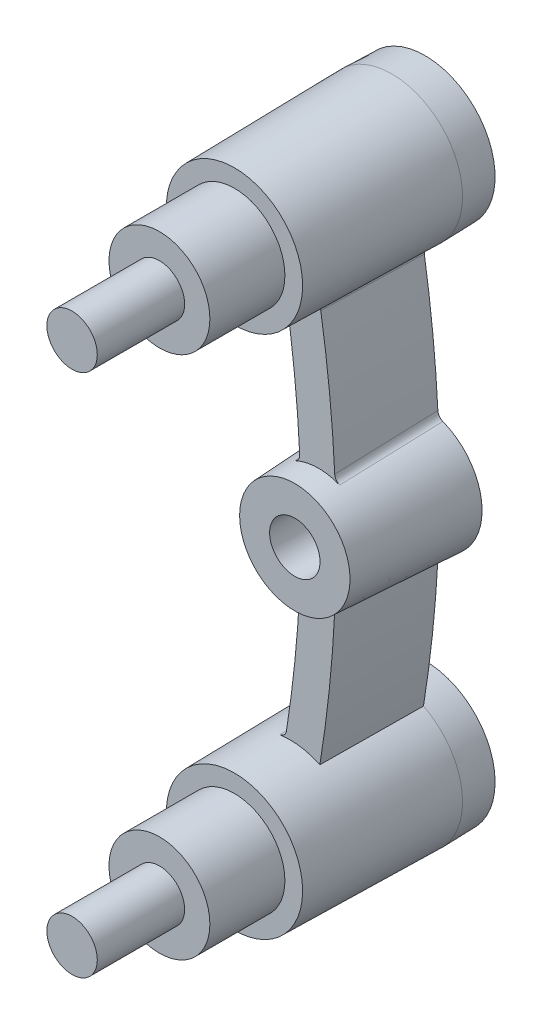
from build123d import *

# Parameters (mm, degrees)
SKETCH1_R             = 4.5
BOSS_EXTRUDE1_DEPTH   = 12
BOSS_EXTRUDE1_TAPER   = 1
BOSS_EXTRUDE1_2_DEPTH = 12
BOSS_EXTRUDE1_2_TAPER = 1
EXTRUDE_THIN1_DEPTH   = 8.5
EXTRUDE_THIN1_TAPER   = 1
SKETCH3_R             = 3.175
BOSS_EXTRUDE2_DEPTH   = 4.72352
SKETCH4_R             = 1.5875
BOSS_EXTRUDE3_DEPTH   = 5.5
SKETCH5_R             = 4
BOSS_EXTRUDE4_DEPTH   = 10
BOSS_EXTRUDE4_TAPER   = 3
SKETCH6_R             = 1.5875
CUT_EXTRUDE2_DEPTH    = 23.22352
SKETCH8_W             = 24.293622
SKETCH8_H             = 48.576804
CUT_EXTRUDE3_DEPTH    = 2.1016
CUT_EXTRUDE3_TAPER    = 3
FILLET3_R             = 0.5
SKETCH9_R             = 4.463316
BOSS_EXTRUDE5_DEPTH   = 2.1016
BOSS_EXTRUDE5_TAPER   = 1.5


with BuildPart() as part:
    # Sketch1 → Boss-Extrude1 (new body)
    with BuildSketch(Plane.XY):
        with Locations((0, -16.5)):
            Circle(SKETCH1_R)
    extrude(amount=BOSS_EXTRUDE1_DEPTH, taper=BOSS_EXTRUDE1_TAPER)



with BuildPart() as body_2:
    # Sketch1 → Boss-Extrude1 2 (new body)
    with BuildSketch(Plane.XY):
        with Locations((0, 16.5)):
            Circle(SKETCH1_R)
    extrude(amount=BOSS_EXTRUDE1_2_DEPTH, taper=BOSS_EXTRUDE1_2_TAPER)


with BuildPart() as part_1:
    add(part.part)

    add(body_2.part)  # Extrude-Thin1 merges body 2
    # Sketch2 → Extrude-Thin1 (add)
    with BuildSketch(Plane.XY):
        with BuildLine():
            ThreePointArc((-1.220598, 16.23048), (0.55, 0), (-1.220598, -16.23048))
            Line((-1.220598, -16.23048), (1.220598, -16.76952))
            ThreePointArc((1.220598, -16.76952), (3.05, 0), (1.220598, 16.76952))
            Line((1.220598, 16.76952), (-1.220598, 16.23048))
        make_face()
    extrude(amount=EXTRUDE_THIN1_DEPTH, taper=EXTRUDE_THIN1_TAPER)

    # Sketch3 → Boss-Extrude2 (add)
    with BuildSketch(Plane.XY.offset(12)):
        with Locations((0, 16.5)):
            Circle(SKETCH3_R)
        with Locations((0, -16.5)):
            Circle(SKETCH3_R)
    extrude(amount=BOSS_EXTRUDE2_DEPTH)

    # Sketch4 → Boss-Extrude3 (add)
    with BuildSketch(Plane.XY.offset(16.72352)):
        with Locations((0, 16.5)):
            Circle(SKETCH4_R)
        with Locations((0, -16.5)):
            Circle(SKETCH4_R)
    extrude(amount=BOSS_EXTRUDE3_DEPTH)

    # Sketch5 → Boss-Extrude4 (add)
    with BuildSketch(Plane(origin=(0, 0, 0), x_dir=(-1, 0, 0), z_dir=(0, 0, -1))):
        with Locations((-1.8, 0)):
            Circle(SKETCH5_R)
    extrude(amount=-BOSS_EXTRUDE4_DEPTH, taper=BOSS_EXTRUDE4_TAPER)

    # Sketch6 → Cut-Extrude2 (cut, through all)
    with BuildSketch(Plane(origin=(0, 0, 0), x_dir=(-1, 0, 0), z_dir=(0, 0, -1))):
        with Locations((-1.8, 0)):
            Circle(SKETCH6_R)
    extrude(amount=-CUT_EXTRUDE2_DEPTH, mode=Mode.SUBTRACT)

    # Sketch8 → Cut-Extrude3 (cut)
    with BuildSketch(Plane(origin=(0, 0, 0), x_dir=(-1, 0, 0), z_dir=(0, 0, -1))):
        with Locations((-1.8, 0)):
            Rectangle(SKETCH8_W, SKETCH8_H)
    extrude(amount=-CUT_EXTRUDE3_DEPTH, taper=CUT_EXTRUDE3_TAPER, mode=Mode.SUBTRACT)

    # Fillet3
    fillet3_edges = [part_1.edges().sort_by_distance(p)[0] for p in [
        (2.875704, -3.563371, 5.3008),
        (0.560755, -3.509846, 5.3008),
        (0.560755, 3.509846, 5.3008),
        (2.875704, 3.563371, 5.3008),
        (1.938379, 12.541653, 5.300803),
        (-0.335993, -12.105351, 5.300803),
    ]]
    fillet(fillet3_edges, radius=FILLET3_R)

    # Sketch9 → Boss-Extrude5 (add)
    with BuildSketch(Plane(origin=(0, 0, 2.1016), x_dir=(-1, 0, 0), z_dir=(0, 0, -1))):
        with Locations((0, 16.5)):
            Circle(SKETCH9_R)
        with Locations((0, -16.5)):
            Circle(SKETCH9_R)
    extrude(amount=BOSS_EXTRUDE5_DEPTH, taper=BOSS_EXTRUDE5_TAPER)


solid = part_1.part
